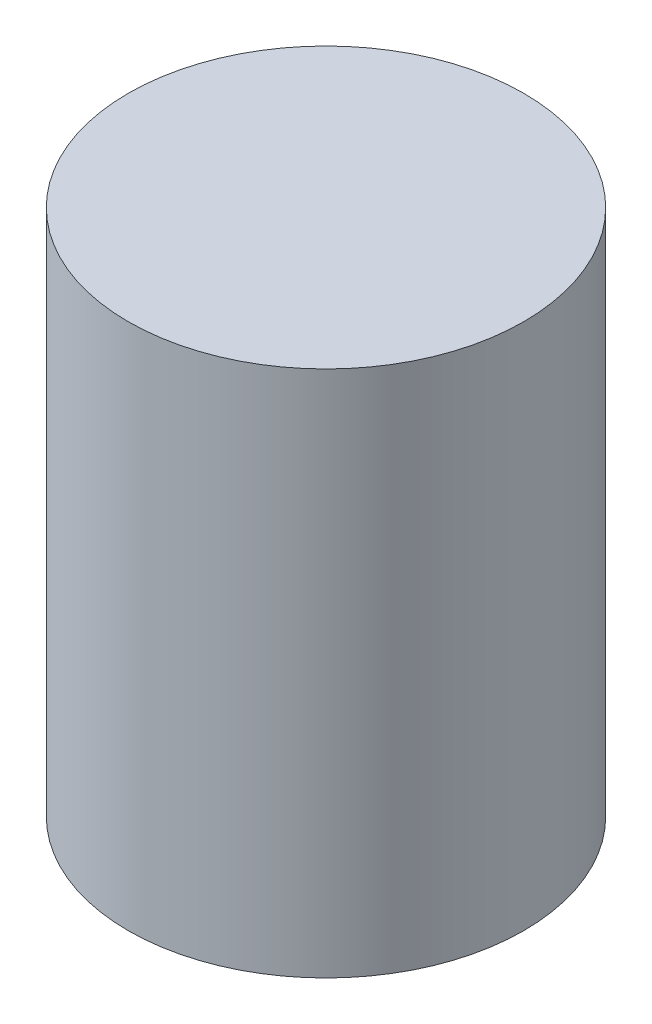
from build123d import *

# Parameters (mm, degrees)
CROQUIS1_R              = 15
SALIENTE_EXTRUIR1_DEPTH = 40


with BuildPart() as part:
    # Croquis1 → Saliente-Extruir1 (new body)
    with BuildSketch(Plane(origin=(0, 0, 0), x_dir=(1, 0, 0), z_dir=(0, 1, 0))):
        Circle(CROQUIS1_R)
    extrude(amount=SALIENTE_EXTRUIR1_DEPTH)


solid = part.part
